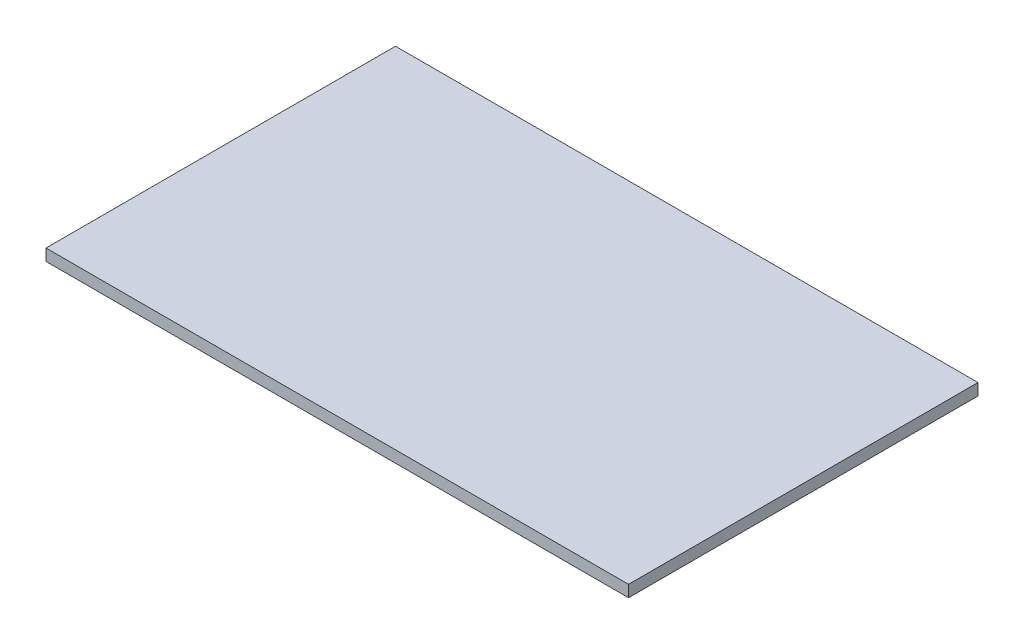
from build123d import *

# Parameters (mm, degrees)
ESQUISSE1_W        = 500
ESQUISSE1_H        = 300
BOSS_EXTRU_1_DEPTH = 10


with BuildPart() as part:
    # Esquisse1 → Boss.-Extru.1 (new body)
    with BuildSketch(Plane(origin=(0, 0, 0), x_dir=(1, 0, 0), z_dir=(0, 1, 0))):
        with Locations((250, 150)):
            Rectangle(ESQUISSE1_W, ESQUISSE1_H)
    extrude(amount=BOSS_EXTRU_1_DEPTH)


solid = part.part
